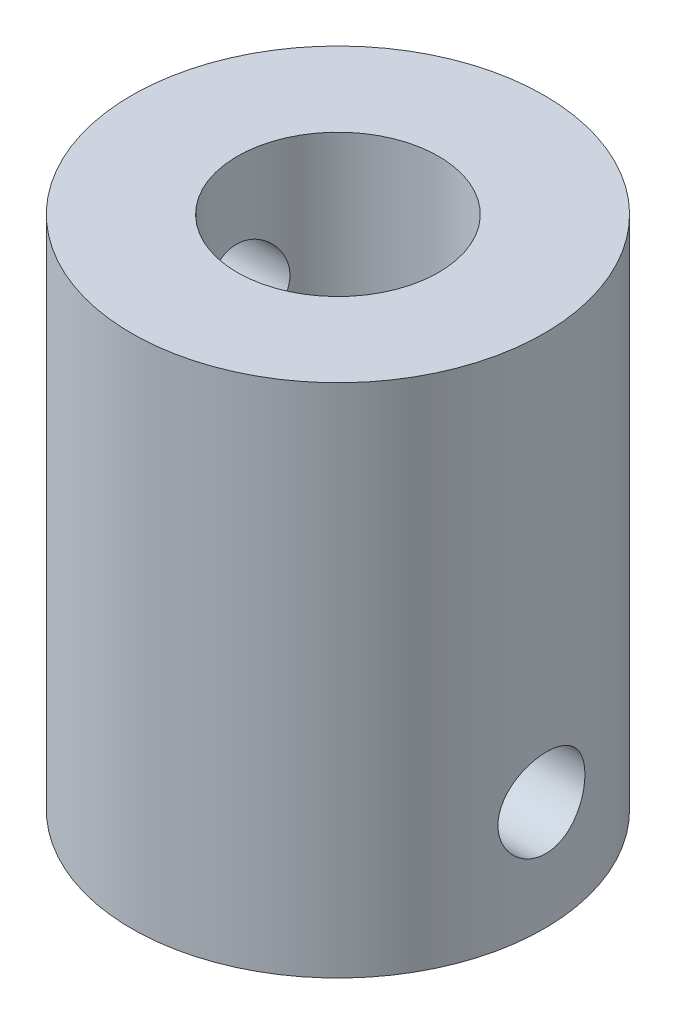
from build123d import *

# Parameters (mm, degrees)
SKETCH1_R                 = 6.35
BOSS_EXTRUDE1_DEPTH       = 15.875
SKETCH2_R                 = 3.1
CUT_EXTRUDE1_DEPTH        = 9.525
SKETCH3_R                 = 4.1
CUT_EXTRUDE2_DEPTH        = 6.35
F_6_32_TAPPED_HOLE1_D     = 2.7051
F_6_32_TAPPED_HOLE1_DEPTH = 7
F_6_32_TAPPED_HOLE1_TIP   = 0.81269403
F_6_32_TAPPED_HOLE2_D     = 2.7051


with BuildPart() as part:
    # Sketch1 → Boss-Extrude1 (new body)
    with BuildSketch(Plane(origin=(0, 0, 0), x_dir=(0, 0, -1), z_dir=(0, -1, 0))):
        Circle(SKETCH1_R)
    extrude(amount=BOSS_EXTRUDE1_DEPTH)

    # Sketch2 → Cut-Extrude1 (cut)
    with BuildSketch(Plane(origin=(0, 0, 0), x_dir=(1, 0, 0), z_dir=(0, 1, 0))):
        Circle(SKETCH2_R)
    extrude(amount=-CUT_EXTRUDE1_DEPTH, mode=Mode.SUBTRACT)

    # Sketch3 → Cut-Extrude2 (cut)
    with BuildSketch(Plane.XZ.offset(15.875)):
        Circle(SKETCH3_R)
    extrude(amount=-CUT_EXTRUDE2_DEPTH, mode=Mode.SUBTRACT)

    # #6-32 Tapped Hole1
    with Locations(Plane(origin=(-6.349702391, -3.685069286, 0.061478042), x_dir=(-0.009681581, 0, -0.999953132), z_dir=(-0.999953132, 0, 0.009681581))):
        with Locations((0, 0)):
            Hole(F_6_32_TAPPED_HOLE1_D / 2, depth=F_6_32_TAPPED_HOLE1_DEPTH)
            with Locations((0, 0, -(F_6_32_TAPPED_HOLE1_DEPTH + F_6_32_TAPPED_HOLE1_TIP / 2))):  # 118° drill point
                Cone(0, F_6_32_TAPPED_HOLE1_D / 2, F_6_32_TAPPED_HOLE1_TIP, mode=Mode.SUBTRACT)

    # #6-32 Tapped Hole2 (through all)
    with Locations(Plane(origin=(-6.349688123, -12.545322132, 0.062934409), x_dir=(-0.009910931, 0, -0.999950886), z_dir=(-0.999950886, 0, 0.009910931))):
        with Locations((0, 0)):
            Hole(F_6_32_TAPPED_HOLE2_D / 2)


solid = part.part
